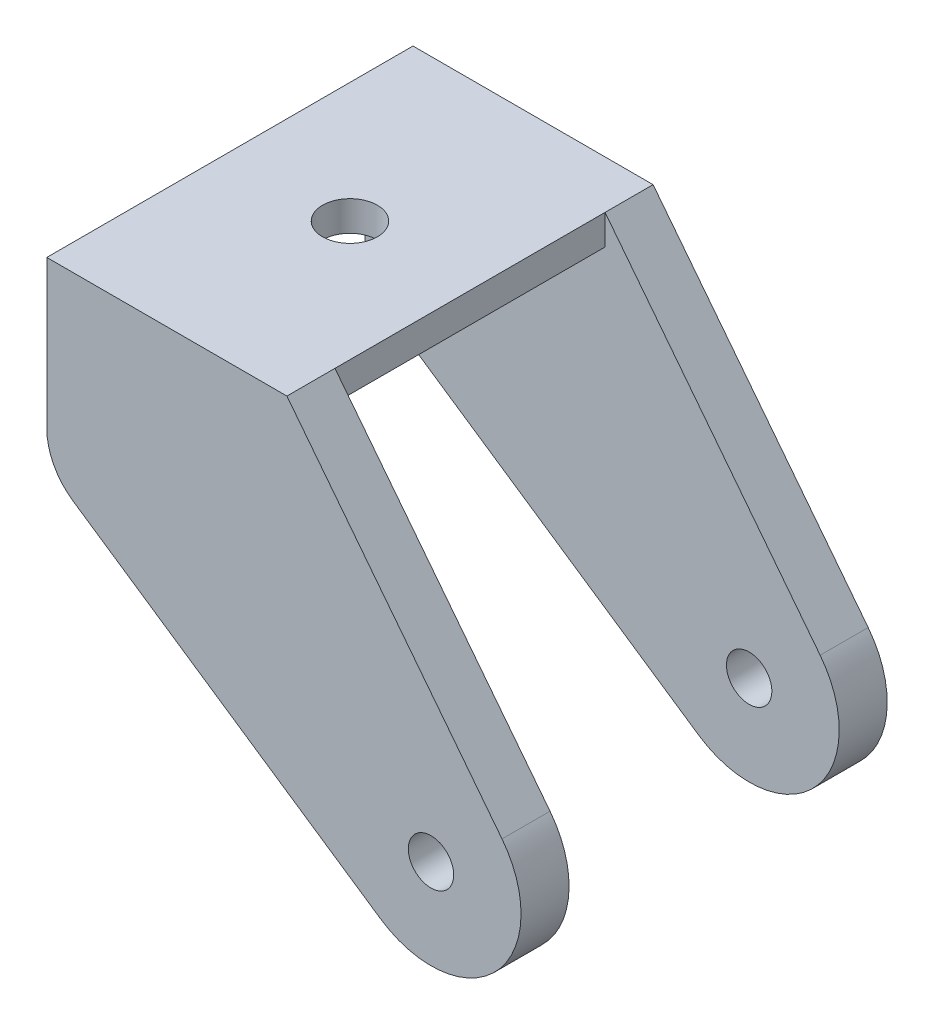
from build123d import *

# Parameters (mm, degrees)
SKETCH1_W            = 25.4
SKETCH1_H            = 19.05
SKETCH1_R            = 9.525
BOSS_EXTRUDE1_DEPTH  = 5.08
M4_CLEARANCE_HOLE1_D = 4.8
SKETCH4_W            = 25.4
SKETCH4_H            = 3.175
BOSS_EXTRUDE2_DEPTH  = 14.2875
M5_CLEARANCE_HOLE1_D = 5.8
FILLET1_R            = 6.35


with BuildPart() as part:
    # Sketch1 → Boss-Extrude1 (new body)
    with BuildSketch(Plane.XY):
        with Locations((-27.94, 25.527)):
            Rectangle(SKETCH1_W, SKETCH1_H)
        with BuildLine():
            Line((-15.24, 16.002), (-40.64, 16.002))
            Line((-40.64, 16.002), (-5.338467717, -7.888370392))
            ThreePointArc((-5.338467717, -7.888370392), (-6.957108321, 6.505710477), (7.51306662, 5.854865922))
            Line((7.51306662, 5.854865922), (-15.24, 35.052))
            Line((-15.24, 35.052), (-15.24, 16.002))
        make_face()
        Circle(SKETCH1_R)
    extrude(amount=BOSS_EXTRUDE1_DEPTH)

    # M4 Clearance Hole1 (through all)
    with Locations(Plane(origin=(0, 0, 0), x_dir=(-1, 0, 0), z_dir=(0, 0, -1))):
        with Locations((0, 0)):
            Hole(M4_CLEARANCE_HOLE1_D / 2)

    # Sketch4 → Boss-Extrude2 (add)
    with BuildSketch(Plane.XY.offset(5.08)):
        with Locations((-27.94, 33.4645)):
            Rectangle(SKETCH4_W, SKETCH4_H)
    extrude(amount=BOSS_EXTRUDE2_DEPTH)

    # Mirror3: part across plane


with BuildPart() as part_1:
    add(part.part)
    add(part.part.mirror(Plane.XY.offset(19.3675)))

    # M5 Clearance Hole1 (through all)
    with Locations(Plane(origin=(0, 35.052, 0), x_dir=(1, 0, 0), z_dir=(0, 1, 0))):
        with Locations((-27.94, -19.3675)):
            Hole(M5_CLEARANCE_HOLE1_D / 2)

    # Fillet1
    fillet1_edges = [part_1.edges().sort_by_distance(p)[0] for p in [
        (-40.64, 16.002, 2.54),
        (-40.64, 16.002, 36.195),
    ]]
    fillet(fillet1_edges, radius=FILLET1_R)


solid = part_1.part
